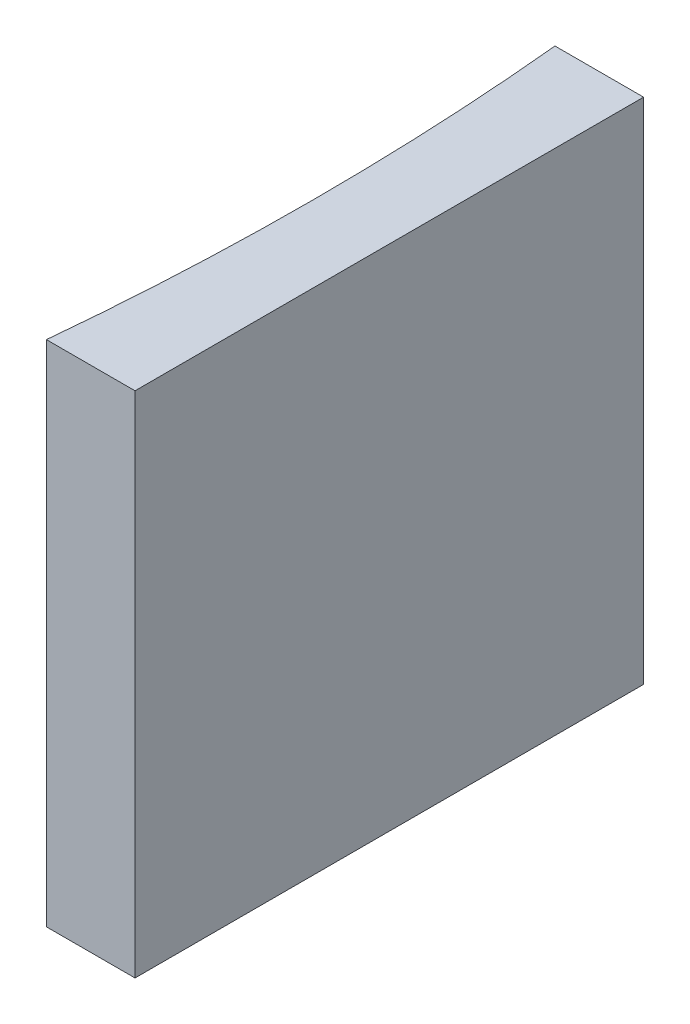
from build123d import *

# Parameters (mm, degrees)
EXTRUDE_1_DEPTH = 20


with BuildPart() as part:
    # 草图1 → 凸台-拉伸1 (new body)
    with BuildSketch(Plane(origin=(0, 0, 0), x_dir=(1, 0, 0), z_dir=(0, 1, 0))):
        with BuildLine():
            Line((0, 0), (0, -20))
            Line((0, -20), (-3.484695016, -20))
            ThreePointArc((-3.484695016, -20), (-3, -10), (-3.484695016, 0))
            Line((-3.484695016, 0), (0, 0))
        make_face()
    extrude(amount=EXTRUDE_1_DEPTH)


solid = part.part
